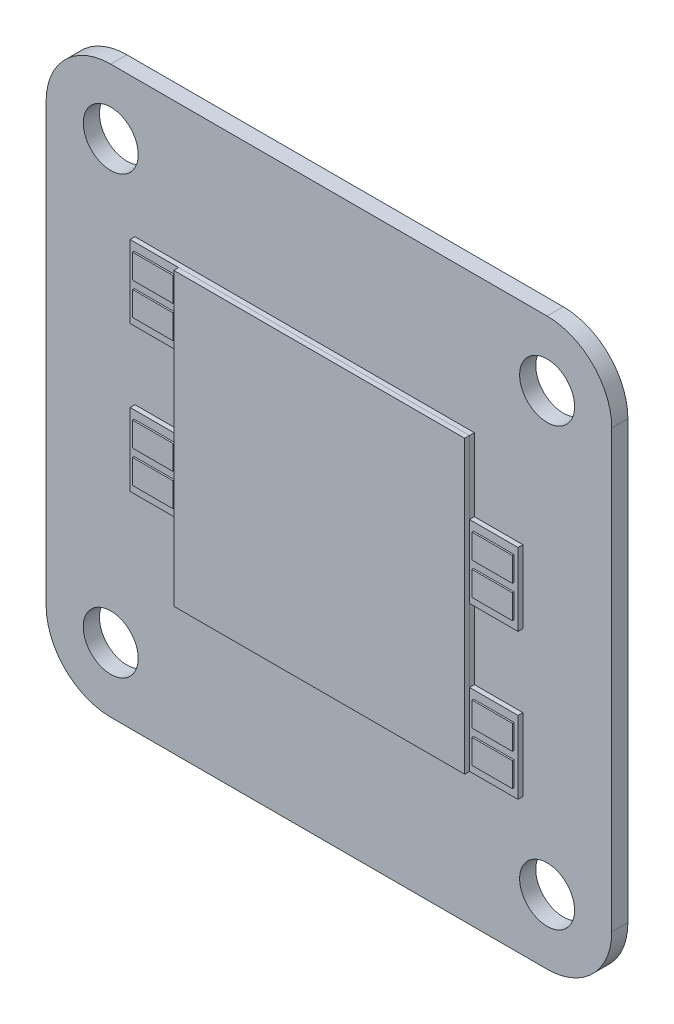
from build123d import *

# Parameters (mm, degrees)
SKETCH_20_R         = 1.7
BOSS_EXTRUDE1_DEPTH = 1
BOSS_EXTRUDE2_DEPTH = 0.3
SKETCH1_W           = 18
SKETCH1_H           = 18
BOSS_EXTRUDE3_DEPTH = 0.3
SKETCH2_W           = 2.5
SKETCH2_H           = 1.5
BOSS_EXTRUDE4_DEPTH = 0.1


with BuildPart() as part:
    # Sketch 20 → Boss-Extrude1 (new body)
    with BuildSketch(Plane.XY):
        with BuildLine():
            Line((4, 0), (31, 0))
            ThreePointArc((31, 0), (33.828427125, 1.171572875), (35, 4))
            Line((35, 4), (35, 31))
            ThreePointArc((35, 31), (33.828427125, 33.828427125), (31, 35))
            Line((31, 35), (4, 35))
            ThreePointArc((4, 35), (1.171572875, 33.828427125), (0, 31))
            Line((0, 31), (0, 4))
            ThreePointArc((0, 4), (1.171572875, 1.171572875), (4, 0))
        make_face()
        with Locations((4, 4)):
            Circle(SKETCH_20_R, mode=Mode.SUBTRACT)
        with Locations((31, 4)):
            Circle(SKETCH_20_R, mode=Mode.SUBTRACT)
        with Locations((31, 31)):
            Circle(SKETCH_20_R, mode=Mode.SUBTRACT)
        with Locations((4, 31)):
            Circle(SKETCH_20_R, mode=Mode.SUBTRACT)
    extrude(amount=BOSS_EXTRUDE1_DEPTH)

    # Sketch 29 → Boss-Extrude2 (add)
    with BuildSketch(Plane.XY.offset(1)):
        Polygon((29.5, 8.5), (8.5, 8.5), (8.5, 13), (5.5, 13), (5.5, 17.5), (8.5, 17.5), (8.5, 22), (5.5, 22), (5.5, 26.5), (26.5, 26.5), (26.5, 22), (29.5, 22), (29.5, 17.5), (26.5, 17.5), (26.5, 13), (29.5, 13), align=None)
    extrude(amount=BOSS_EXTRUDE2_DEPTH)

    # Sketch2 → Boss-Extrude4 (add)
    with BuildSketch(Plane.XY.offset(1.3)):
        with Locations((28, 9.75)):
            Rectangle(SKETCH2_W, SKETCH2_H)
        with Locations((28, 11.75)):
            Rectangle(SKETCH2_W, SKETCH2_H)
        with Locations((28, 18.75)):
            Rectangle(SKETCH2_W, SKETCH2_H)
        with Locations((28, 20.75)):
            Rectangle(SKETCH2_W, SKETCH2_H)
        with Locations((7, 14.25)):
            Rectangle(SKETCH2_W, SKETCH2_H)
        with Locations((7, 23.25)):
            Rectangle(SKETCH2_W, SKETCH2_H)
        with Locations((7, 16.25)):
            Rectangle(SKETCH2_W, SKETCH2_H)
        with Locations((7, 25.25)):
            Rectangle(SKETCH2_W, SKETCH2_H)
    extrude(amount=BOSS_EXTRUDE4_DEPTH)


with BuildPart() as body_2:
    # Sketch1 → Boss-Extrude3 (new body)
    with BuildSketch(Plane.XY.offset(1.3)):
        with Locations((17.5, 17.5)):
            Rectangle(SKETCH1_W, SKETCH1_H)
    extrude(amount=BOSS_EXTRUDE3_DEPTH)


solid = Compound([part.part, body_2.part])
